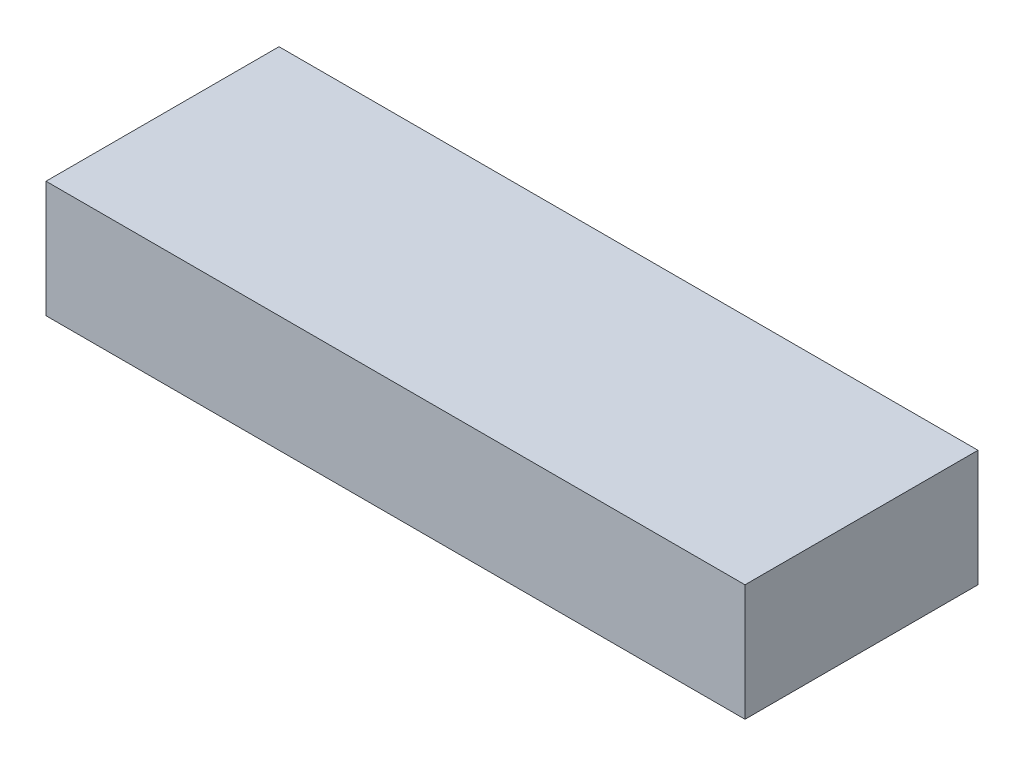
from build123d import *

# Parameters (mm, degrees)
SKETCH2_W           = 152.4
SKETCH2_H           = 50.8
BOSS_EXTRUDE2_DEPTH = 25.4


with BuildPart() as part:
    # Sketch2 → Boss-Extrude2 (new body)
    with BuildSketch(Plane(origin=(0, 0, 0), x_dir=(1, 0, 0), z_dir=(0, 1, 0))):
        with Locations((76.2, 25.4)):
            Rectangle(SKETCH2_W, SKETCH2_H)
    extrude(amount=BOSS_EXTRUDE2_DEPTH)


solid = part.part
